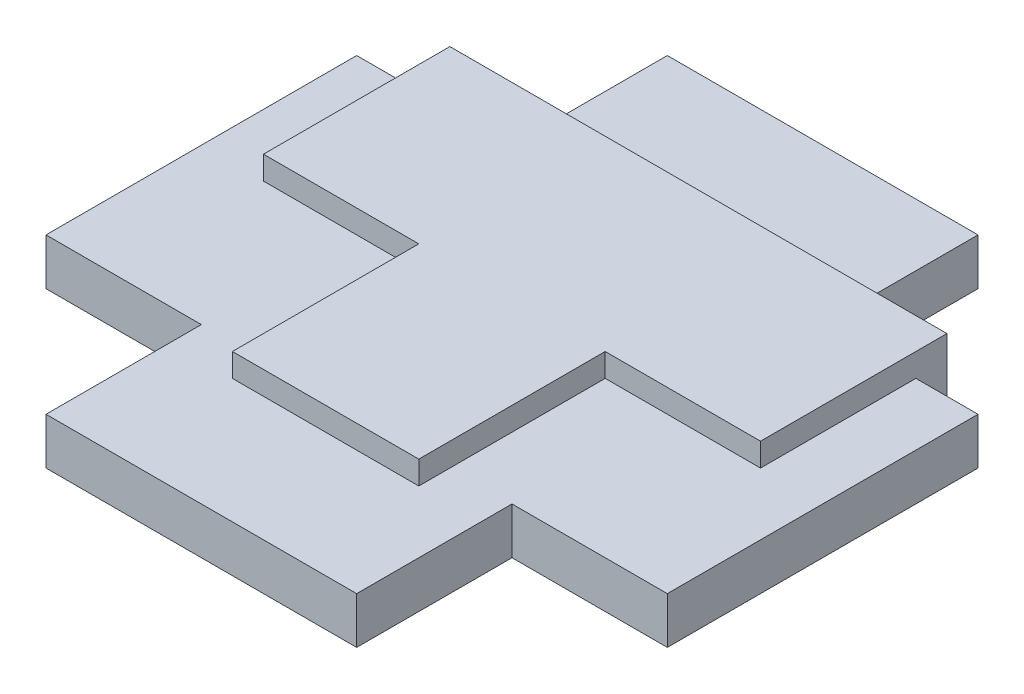
from build123d import *

# Parameters (mm, degrees)
SKETCH1_W                = 6
SKETCH1_H                = 6
SKETCH1_W_2              = 16
BOSS_EXTRUDE2_DEPTH      = 3
SKETCH4_W                = 5
SKETCH4_H                = 10
SKETCH4_W_2              = 10
SKETCH4_H_2              = 5
BOSS_EXTRUDE3_DEPTH      = 0.75
BOSS_EXTRUDE3_DEPTH_BACK = 0.75


with BuildPart() as part:
    # Sketch1 → Boss-Extrude2 (new body)
    with BuildSketch(Plane(origin=(0, 0, 0), x_dir=(1, 0, 0), z_dir=(0, 1, 0))):
        with Locations((0, -3)):
            Rectangle(SKETCH1_W, SKETCH1_H)
        with Locations((0, 3)):
            Rectangle(SKETCH1_W_2, SKETCH1_H)
    extrude(amount=BOSS_EXTRUDE2_DEPTH)

    # Sketch4 → Boss-Extrude3 (add, two sides)
    with BuildSketch(Plane(origin=(0, 1.5, 0), x_dir=(1, 0, 0), z_dir=(0, 1, 0))) as boss_extrude3_sk:
        with Locations((-7.5, 0)):
            Rectangle(SKETCH4_W, SKETCH4_H)
        Rectangle(SKETCH4_W_2, SKETCH4_H)
        with Locations((0, 7.5)):
            Rectangle(SKETCH4_W_2, SKETCH4_H_2)
        with Locations((7.5, 0)):
            Rectangle(SKETCH4_W, SKETCH4_H)
        with Locations((0, -7.5)):
            Rectangle(SKETCH4_W_2, SKETCH4_H_2)
    extrude(amount=BOSS_EXTRUDE3_DEPTH)
    extrude(boss_extrude3_sk.sketch, amount=-BOSS_EXTRUDE3_DEPTH_BACK)


solid = part.part
